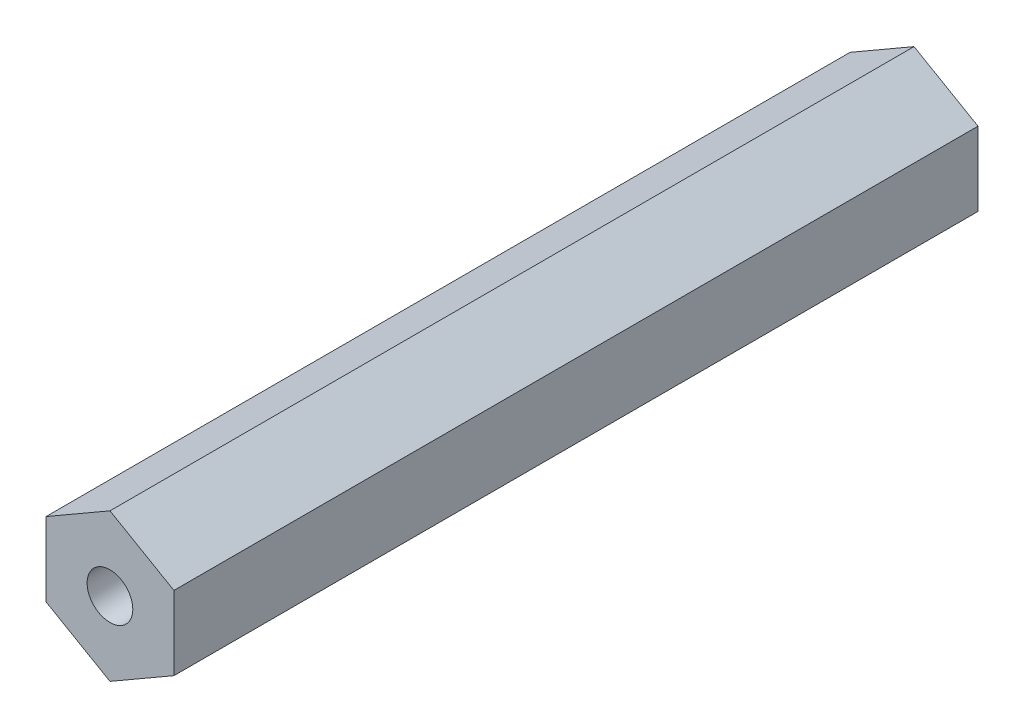
from build123d import *

# Parameters (mm, degrees)
BOSS_EXTRUDE1_DEPTH = 44
SKETCH2_R           = 1.25
CUT_EXTRUDE1_DEPTH  = 5
SKETCH3_R           = 1.25
CUT_EXTRUDE2_DEPTH  = 5


with BuildPart() as part:
    # Sketch1 → Boss-Extrude1 (new body)
    with BuildSketch(Plane.XY):
        Polygon((0, -4.041451884), (3.5, -2.020725942), (3.5, 2.020725942), (0, 4.041451884), (-3.5, 2.020725942), (-3.5, -2.020725942), align=None)
    extrude(amount=BOSS_EXTRUDE1_DEPTH)

    # Sketch2 → Cut-Extrude1 (cut)
    with BuildSketch(Plane.XY.offset(44)):
        Circle(SKETCH2_R)
    extrude(amount=-CUT_EXTRUDE1_DEPTH, mode=Mode.SUBTRACT)

    # Sketch3 → Cut-Extrude2 (cut)
    with BuildSketch(Plane(origin=(0, 0, 0), x_dir=(-1, 0, 0), z_dir=(0, 0, -1))):
        Circle(SKETCH3_R)
    extrude(amount=-CUT_EXTRUDE2_DEPTH, mode=Mode.SUBTRACT)


solid = part.part
